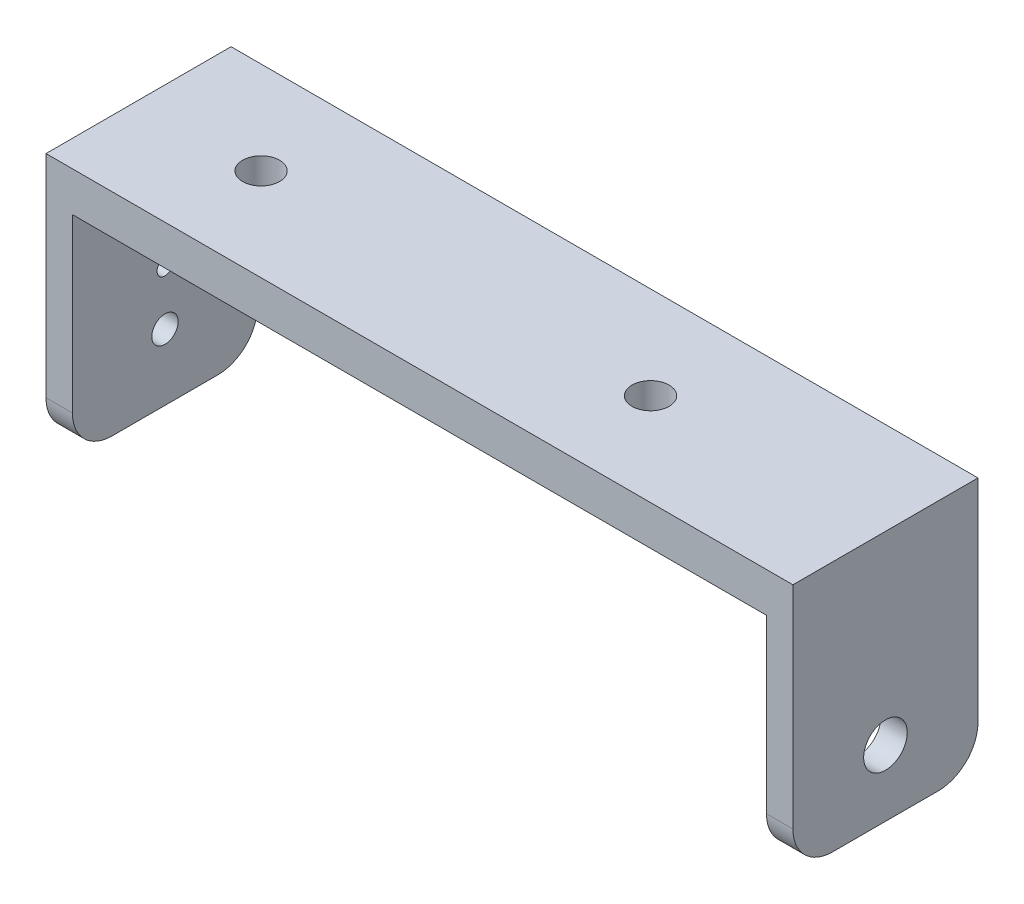
from build123d import *

# Parameters (mm, degrees)
EXTRUDE_1_DEPTH     = 14
SKETCH_2_R          = 1.65
CUT_EXTRUDE_1_DEPTH = 2
SKETCH_3_R          = 1.4
CUT_EXTRUDE_2_DEPTH = 14
FILLET_1_R          = 3
SKETCH_5_R          = 0.6
SKETCH_5_R_2        = 1
CUT_EXTRUDE_3_DEPTH = 10


with BuildPart() as part:
    # 草图1 → 凸台-拉伸1 (new body)
    with BuildSketch(Plane.XY):
        Polygon((-28.25, 0), (-28.25, 19), (28.25, 19), (28.25, 0), (26.25, 0), (26.25, 16), (-26.25, 16), (-26.25, 0), align=None)
    extrude(amount=EXTRUDE_1_DEPTH)

    # 草图2 → 切除-拉伸1 (cut)
    with BuildSketch(Plane(origin=(28.25, 0, 0), x_dir=(0, 0, -1), z_dir=(1, 0, 0))):
        with Locations((-7, 5)):
            Circle(SKETCH_2_R)
    extrude(amount=-CUT_EXTRUDE_1_DEPTH, mode=Mode.SUBTRACT)

    # 草图3 → 切除-拉伸2 (cut)
    with BuildSketch(Plane(origin=(0, 19, 0), x_dir=(1, 0, 0), z_dir=(0, 1, 0))):
        with Locations((-18.98, -7)):
            Circle(SKETCH_3_R)
        with Locations((10.48, -7)):
            Circle(SKETCH_3_R)
    extrude(amount=-CUT_EXTRUDE_2_DEPTH, mode=Mode.SUBTRACT)

    # 圆角1
    fillet_1_edges = [part.edges().sort_by_distance(p)[0] for p in [
        (-27.25, 0, 0),
        (27.25, 0, 0),
        (27.25, 0, 14),
        (-27.25, 0, 14),
    ]]
    fillet(fillet_1_edges, radius=FILLET_1_R)

    # 草图5 → 切除-拉伸3 (cut)
    with BuildSketch(Plane.ZY.offset(28.25)):
        with Locations((7, 9.085)):
            Circle(SKETCH_5_R)
        with Locations((7, 13.085)):
            Circle(SKETCH_5_R)
        with Locations((7, 5)):
            Circle(SKETCH_5_R_2)
    extrude(amount=-CUT_EXTRUDE_3_DEPTH, mode=Mode.SUBTRACT)


solid = part.part
